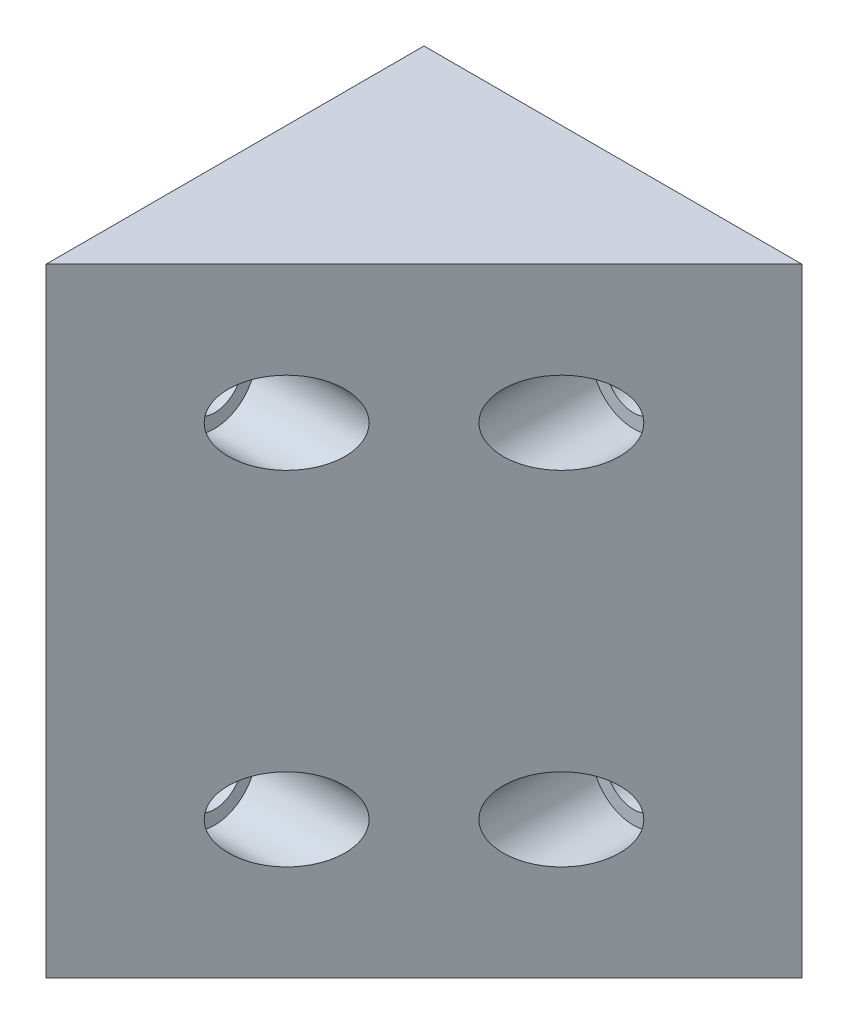
from build123d import *

# Parameters (mm, degrees)
BOSS_EXTRUDE1_DEPTH = 100
SKETCH2_R           = 6
CUT_EXTRUDE1_DEPTH  = 43
SKETCH4_R           = 4
CUT_EXTRUDE2_DEPTH  = 7
SKETCH6_R           = 4
CUT_EXTRUDE3_DEPTH  = 7
SKETCH7_W           = 55
SKETCH7_H           = 5
CUT_EXTRUDE4_DEPTH  = 55


with BuildPart() as part:
    # Sketch1 → Boss-Extrude1 (new body)
    with BuildSketch(Plane(origin=(0, 0, 0), x_dir=(1, 0, 0), z_dir=(0, 1, 0))):
        Polygon((0, 0), (55, 55), (0, 55), align=None)
    extrude(amount=BOSS_EXTRUDE1_DEPTH)

    # Sketch2 → Cut-Extrude1 (cut)
    with BuildSketch(Plane(origin=(50, 0, 0), x_dir=(0, 0, -1), z_dir=(1, 0, 0))):
        with Locations((17.5, 25)):
            Circle(SKETCH2_R)
        with Locations((17.5, 75)):
            Circle(SKETCH2_R)
    cut_extrude1 = extrude(amount=-CUT_EXTRUDE1_DEPTH, mode=Mode.SUBTRACT)

    # Sketch4 → Cut-Extrude2 (cut)
    with BuildSketch(Plane(origin=(7, 0, 0), x_dir=(0, 0, -1), z_dir=(1, 0, 0))):
        with Locations((17.5, 75)):
            Circle(SKETCH4_R)
        with Locations((17.5, 25)):
            Circle(SKETCH4_R)
    extrude(amount=-CUT_EXTRUDE2_DEPTH, mode=Mode.SUBTRACT)

    # Mirror6: Cut-Extrude1 across plane
    add(cut_extrude1.mirror(Plane(origin=(27.5, 0, -27.5), x_dir=(0.707106781, 0, 0.707106781), z_dir=(-0.707106781, 0, 0.707106781))), mode=Mode.SUBTRACT)

    # Sketch6 → Cut-Extrude3 (cut)
    with BuildSketch(Plane.XY.offset(-48)):
        with Locations((37.5, 75)):
            Circle(SKETCH6_R)
        with Locations((37.5, 25)):
            Circle(SKETCH6_R)
    extrude(amount=-CUT_EXTRUDE3_DEPTH, mode=Mode.SUBTRACT)

    # Sketch7 → Cut-Extrude4 (cut)
    with BuildSketch(Plane.XY):
        with Locations((27.5, 97.5)):
            Rectangle(SKETCH7_W, SKETCH7_H)
        with Locations((27.5, 2.5)):
            Rectangle(SKETCH7_W, SKETCH7_H)
    extrude(amount=-CUT_EXTRUDE4_DEPTH, mode=Mode.SUBTRACT)


solid = part.part
